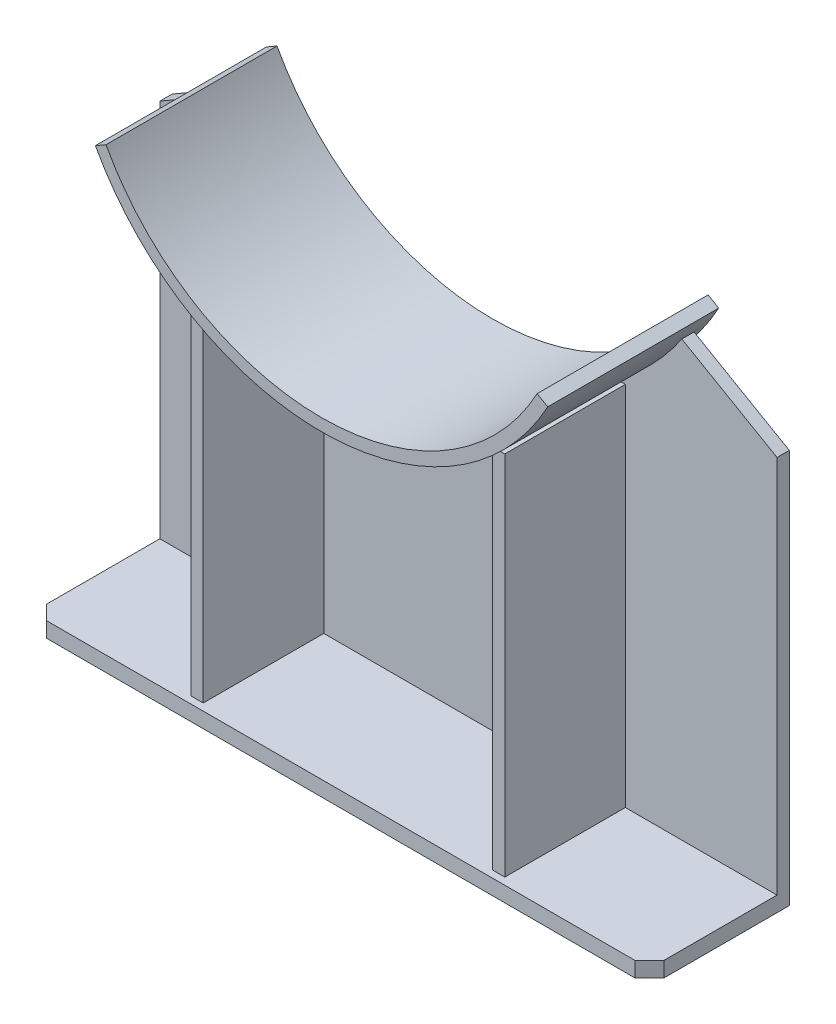
from build123d import *

# Parameters (mm, degrees)
BOSS_EXTRUDE1_DEPTH      = 12.7
BOSS_EXTRUDE2_DEPTH      = 152.3
BOSS_EXTRUDE2_DEPTH_BACK = 25
BOSS_EXTRUDE3_DEPTH      = 15.8
SKETCH4_W                = 12.7
SKETCH4_H                = 380
BOSS_EXTRUDE4_DEPTH      = 125


with BuildPart() as part:
    # Sketch1 → Boss-Extrude1 (new body)
    with BuildSketch(Plane.XY):
        with BuildLine():
            Line((320, 0.313790229), (-320, 0.313790229))
            Line((-320, 0.313790229), (-320, 393.313790229))
            Line((-320, 393.313790229), (-221.273103969, 450.313790229))
            ThreePointArc((-221.273103969, 450.313790229), (0, 332.5), (221.273103969, 450.313790229))
            Line((221.273103969, 450.313790229), (320, 393.313790229))
            Line((320, 393.313790229), (320, 0.313790229))
        make_face()
    extrude(amount=BOSS_EXTRUDE1_DEPTH)

    # Sketch2 → Boss-Extrude2 (add, two sides)
    with BuildSketch(Plane.XY.offset(12.7)) as boss_extrude2_sk:
        with BuildLine():
            Line((234.52055347, 472.2), (223.517731773, 478.552482069))
            ThreePointArc((223.517731773, 478.552482069), (0, 345.2), (-223.517731773, 478.552482069))
            Line((-223.517731773, 478.552482069), (-234.52055347, 472.2))
            ThreePointArc((-234.52055347, 472.2), (0, 332.5), (234.52055347, 472.2))
        make_face()
    extrude(amount=BOSS_EXTRUDE2_DEPTH)
    extrude(boss_extrude2_sk.sketch, amount=-BOSS_EXTRUDE2_DEPTH_BACK)

    # Sketch3 → Boss-Extrude3 (add)
    with BuildSketch(Plane.XZ.offset(-0.313790229)):
        Polygon((-305, -15), (305, -15), (320, 0), (320, 130), (305, 145), (-305, 145), (-320, 130), (-320, 0), align=None)
    extrude(amount=BOSS_EXTRUDE3_DEPTH)

    # Sketch4 → Boss-Extrude4 (add)
    with BuildSketch(Plane.XY.offset(12.7)):
        with Locations((-156.35, 190.313790229)):
            Rectangle(SKETCH4_W, SKETCH4_H)
        with Locations((156.35, 190.313790229)):
            Rectangle(SKETCH4_W, SKETCH4_H)
    extrude(amount=BOSS_EXTRUDE4_DEPTH)


solid = part.part
